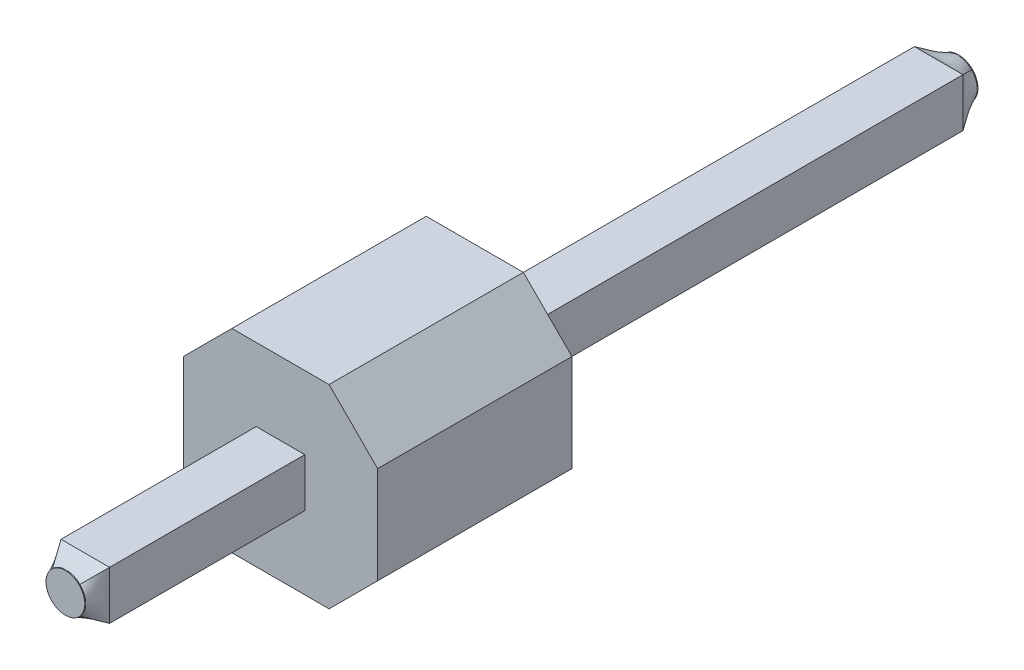
from build123d import *

# Parameters (mm, degrees)
SKETCH1_W           = 0.635
SKETCH1_H           = 0.635
BOSS_EXTRUDE1_DEPTH = 11.157
BOSS_EXTRUDE2_DEPTH = 2.54
SKETCH3_R           = 0.254
SKETCH4_R           = 0.254
SKETCH6_R           = 0.254
BOSS_EXTRUDE3_DEPTH = 0.01
SKETCH7_R           = 0.254
BOSS_EXTRUDE4_DEPTH = 0.01


with BuildPart() as part:
    # Sketch1 → Boss-Extrude1 (new body)
    with BuildSketch(Plane.XY.offset(5.092)):
        Rectangle(SKETCH1_W, SKETCH1_H)
    extrude(amount=-BOSS_EXTRUDE1_DEPTH)

    # Sketch2 → Boss-Extrude2 (add)
    with BuildSketch(Plane.XY):
        Polygon((-1.27, 0.635), (-0.635, 1.27), (0.635, 1.27), (1.27, 0.635), (1.27, -0.635), (0.635, -1.27), (-0.635, -1.27), (-1.27, -0.635), align=None)
    extrude(amount=BOSS_EXTRUDE2_DEPTH)

    # Sketch3 → section 0 of loft1
    with BuildSketch(Plane.XY.offset(5.342), mode=Mode.PRIVATE) as loft1_s0:
        Circle(SKETCH3_R)
    # loft up to a face of the part (loft1)
    loft([loft1_s0.sketch, part.faces().sort_by_distance((0, 0, 5.092))[0]])

    # Sketch4 → section 0 of loft2
    with BuildSketch(Plane(origin=(0, 0, -6.315), x_dir=(-1, 0, 0), z_dir=(0, 0, -1)), mode=Mode.PRIVATE) as loft2_s0:
        Circle(SKETCH4_R)
    # loft up to a face of the part (loft2)
    loft([loft2_s0.sketch, part.faces().sort_by_distance((0, 0, -6.065))[0]])

    # Sketch6 → Boss-Extrude3 (add)
    with BuildSketch(Plane.XY.offset(5.342)):
        Circle(SKETCH6_R)
    extrude(amount=BOSS_EXTRUDE3_DEPTH)

    # Sketch7 → Boss-Extrude4 (add)
    with BuildSketch(Plane(origin=(0, 0, -6.315), x_dir=(-1, 0, 0), z_dir=(0, 0, -1))):
        Circle(SKETCH7_R)
    extrude(amount=BOSS_EXTRUDE4_DEPTH)


solid = part.part
